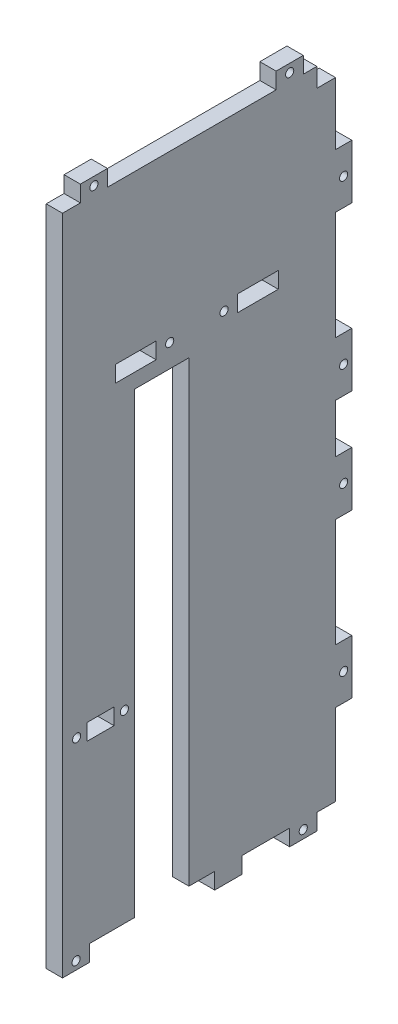
from build123d import *

# Parameters (mm, degrees)
ESQUISSE1_W             = 100.58
ESQUISSE1_H             = 238
ESQUISSE1_W_2           = 10
ESQUISSE1_H_2           = 6
ESQUISSE1_W_3           = 15
BOSS_EXTRU_1_DEPTH      = 6
ESQUISSE3_W             = 10
ESQUISSE3_H             = 6
ESQUISSE3_W_2           = 6
ESQUISSE3_H_2           = 20
BOSS_EXTRU_5_DEPTH      = 6
ESQUISSE6_W             = 20
ESQUISSE6_H             = 168.59
ENL_V_MAT_EXTRU_2_DEPTH = 6
ESQUISSE7_W             = 6.88
ESQUISSE7_H             = 7
ENL_V_MAT_EXTRU_3_DEPTH = 6
ESQUISSE8_R             = 1.5
ENL_V_MAT_EXTRU_4_DEPTH = 6


with BuildPart() as part:
    # Esquisse1 → Boss.-Extru.1 (new body)
    with BuildSketch(Plane(origin=(0, 0, 0), x_dir=(0, 0, -1), z_dir=(1, 0, 0))):
        Rectangle(ESQUISSE1_W, ESQUISSE1_H)
        with Locations((-36.29, -51)):
            Rectangle(ESQUISSE1_W_2, ESQUISSE1_H_2, mode=Mode.SUBTRACT)
        with Locations((-23.295, 58)):
            Rectangle(ESQUISSE1_W_3, ESQUISSE1_H_2, mode=Mode.SUBTRACT)
        with Locations((21.705, 58)):
            Rectangle(ESQUISSE1_W_3, ESQUISSE1_H_2, mode=Mode.SUBTRACT)
    extrude(amount=BOSS_EXTRU_1_DEPTH)

    # Esquisse3 → Boss.-Extru.5 (add)
    with BuildSketch(Plane(origin=(6, 0, 0), x_dir=(0, 0, -1), z_dir=(1, 0, 0))):
        with Locations((-45.29, -122)):
            Rectangle(ESQUISSE3_W, ESQUISSE3_H)
        with Locations((38.41, -122)):
            Rectangle(ESQUISSE3_W, ESQUISSE3_H)
        with Locations((53.29, 19)):
            Rectangle(ESQUISSE3_W_2, ESQUISSE3_H_2)
        with Locations((53.29, 79)):
            Rectangle(ESQUISSE3_W_2, ESQUISSE3_H_2)
        with Locations((53.29, -79)):
            Rectangle(ESQUISSE3_W_2, ESQUISSE3_H_2)
        with Locations((53.29, -19)):
            Rectangle(ESQUISSE3_W_2, ESQUISSE3_H_2)
        with Locations((10.79, -122)):
            Rectangle(ESQUISSE3_W, ESQUISSE3_H)
        with Locations((33.41, 122)):
            Rectangle(ESQUISSE3_W, ESQUISSE3_H)
        with Locations((-38.71, 122)):
            Rectangle(ESQUISSE3_W, ESQUISSE3_H)
    extrude(amount=-BOSS_EXTRU_5_DEPTH)

    # Esquisse6 → Enlèv. mat.-Extru.2 (cut)
    with BuildSketch(Plane(origin=(6, 0, 0), x_dir=(0, 0, -1), z_dir=(1, 0, 0))):
        with Locations((-13.71, -34.705)):
            Rectangle(ESQUISSE6_W, ESQUISSE6_H)
    extrude(amount=-ENL_V_MAT_EXTRU_2_DEPTH, mode=Mode.SUBTRACT)

    # Esquisse7 → Enlèv. mat.-Extru.3 (cut)
    with BuildSketch(Plane.ZY):
        with Locations((-46.85, 115.5)):
            Rectangle(ESQUISSE7_W, ESQUISSE7_H)
    extrude(amount=-ENL_V_MAT_EXTRU_3_DEPTH, mode=Mode.SUBTRACT)

    # Esquisse8 → Enlèv. mat.-Extru.4 (cut)
    with BuildSketch(Plane.ZY):
        with Locations((-9.205, 58)):
            Circle(ESQUISSE8_R)
        with Locations((10.795, 58)):
            Circle(ESQUISSE8_R)
        with Locations((27.5, -51)):
            Circle(ESQUISSE8_R)
        with Locations((45.08, -51)):
            Circle(ESQUISSE8_R)
        with Locations((38.71, 122)):
            Circle(ESQUISSE8_R)
        with Locations((-33.41, 122)):
            Circle(ESQUISSE8_R)
        with Locations((45.29, -122)):
            Circle(ESQUISSE8_R)
        with Locations((-53.29, 79)):
            Circle(ESQUISSE8_R)
        with Locations((-38.41, -122)):
            Circle(ESQUISSE8_R)
        with Locations((-53.29, 19)):
            Circle(ESQUISSE8_R)
        with Locations((-53.29, -79)):
            Circle(ESQUISSE8_R)
        with Locations((-53.29, -19)):
            Circle(ESQUISSE8_R)
    extrude(amount=-ENL_V_MAT_EXTRU_4_DEPTH, mode=Mode.SUBTRACT)


solid = part.part
